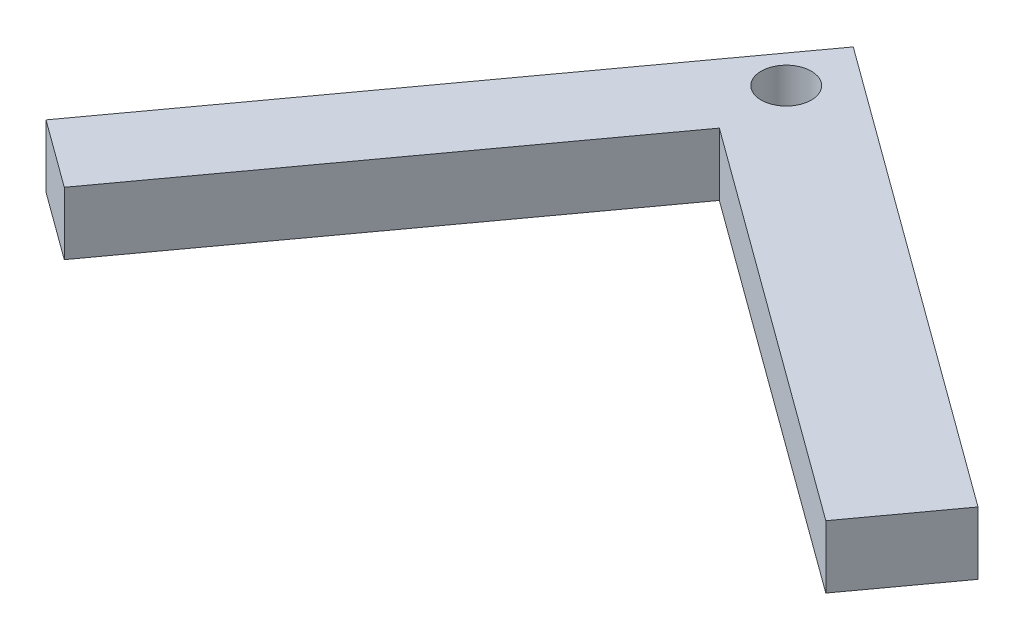
from build123d import *

# Parameters (mm, degrees)
BOSS_EXTRUDE1_DEPTH = 3.81
SKETCH2_R           = 1.524
CUT_EXTRUDE1_DEPTH  = 4.81


with BuildPart() as part:
    # Sketch1 → Boss-Extrude1 (new body)
    with BuildSketch(Plane(origin=(0, 0, 0), x_dir=(1, 0, 0), z_dir=(0, 1, 0))):
        Polygon((0, 0), (-16.791095333, -23.024017908), (-20.895540284, -20.030703417), (-0.203481556, 8.342331293), (27.803264512, -12.082598235), (23.902301118, -17.431615036), align=None)
    extrude(amount=BOSS_EXTRUDE1_DEPTH)

    # Sketch2 → Cut-Extrude1 (cut, through all)
    with BuildSketch(Plane(origin=(0, 3.81, 0), x_dir=(1, 0, 0), z_dir=(0, 1, 0))):
        with Locations((-0.203481556, 4.268280512)):
            Circle(SKETCH2_R)
    extrude(amount=-CUT_EXTRUDE1_DEPTH, mode=Mode.SUBTRACT)


solid = part.part
